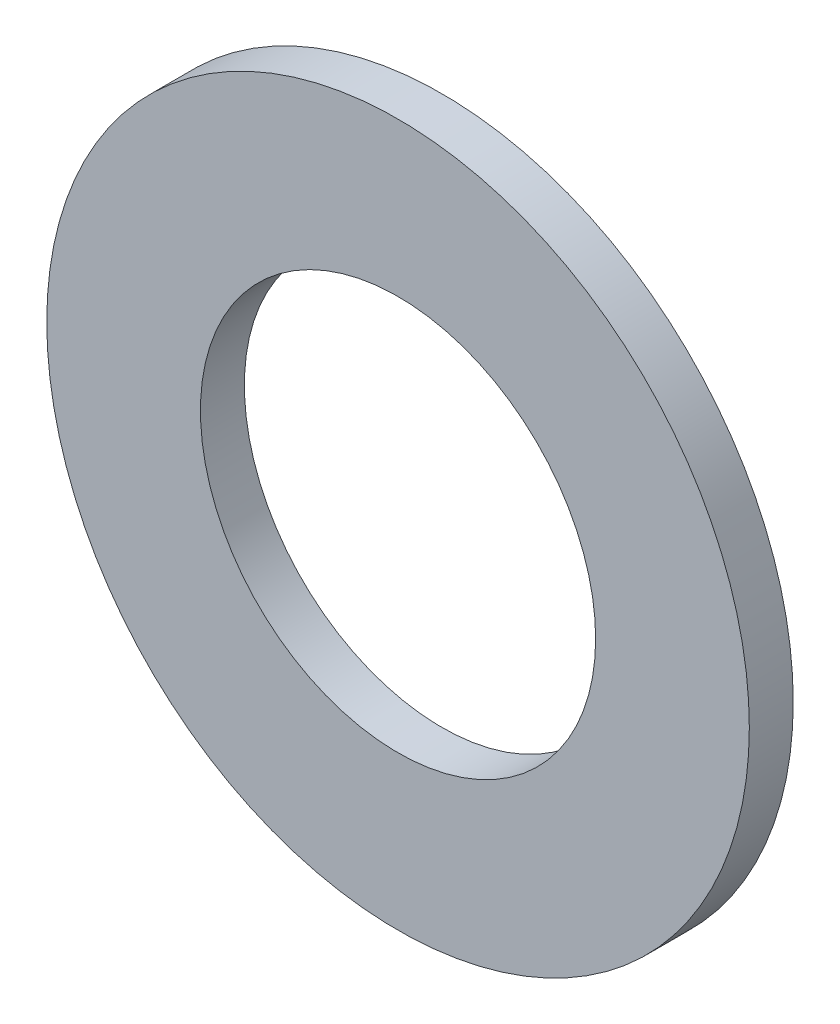
from build123d import *

# Parameters (mm, degrees)
SKETCH_1_R          = 8
EXTRUDE_1_DEPTH     = 1
SKETCH_2_R          = 4.5
CUT_EXTRUDE_1_DEPTH = 2


with BuildPart() as part:
    # 草图1 → 凸台-拉伸1 (new body)
    with BuildSketch(Plane.XY):
        Circle(SKETCH_1_R)
    extrude(amount=EXTRUDE_1_DEPTH)

    # 草图2 → 切除-拉伸1 (cut, through all)
    with BuildSketch(Plane.XY.offset(1)):
        Circle(SKETCH_2_R)
    extrude(amount=-CUT_EXTRUDE_1_DEPTH, mode=Mode.SUBTRACT)


solid = part.part
